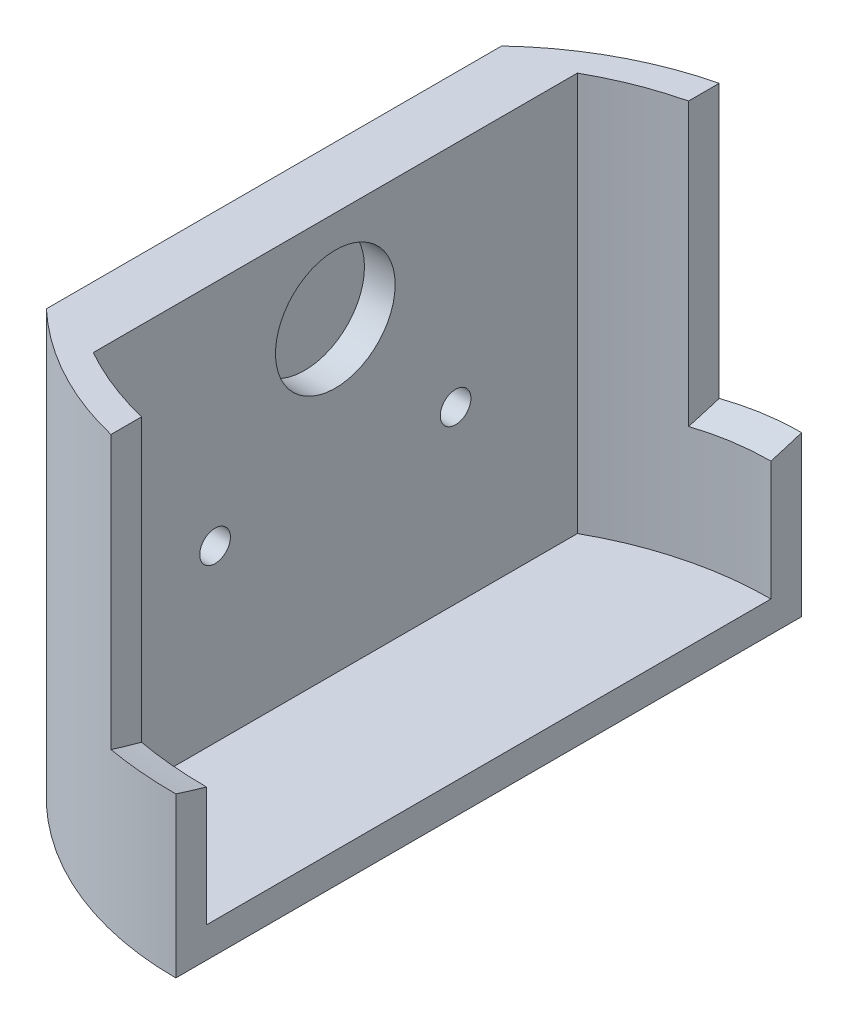
from build123d import *

# Parameters (mm, degrees)
BOSS_EXTRU_7_DEPTH      = 35
BOSS_EXTRU_8_START      = -5
BOSS_EXTRU_8_DEPTH      = 5
ESQUISSE3_R             = 2.4999999999999987
ENL_V_MAT_EXTRU_1_DEPTH = 5
ENL_V_MAT_EXTRU_2_DEPTH = 12
ESQUISSE6_R             = 9.75
ENL_V_MAT_EXTRU_3_DEPTH = 5


with BuildPart() as part:
    # Esquisse1 → Boss.-Extru.7 (new, symmetric)
    with BuildSketch(Plane(origin=(0, 0, 0), x_dir=(1, 0, 0), z_dir=(0, 1, 0))):
        with BuildLine():
            Line((0, 51.00000000000001), (1.188e-14, 46.00000000000001))
            ThreePointArc((1.188e-14, 46.00000000000001), (-12.921623376513631, 44.33590628857987), (-24.99999999999999, 39.45222154178573))
            Line((-24.99999999999999, 39.45222154178573), (-24.99999999999999, -39.45222154178573))
            ThreePointArc((-24.99999999999999, -39.45222154178573), (-12.921623376513633, -44.33590628857988), (1.188e-14, -46.00000000000001))
            Line((1.188e-14, -46.00000000000001), (0, -51.00000000000001))
            ThreePointArc((0, -51.00000000000001), (-18.830584522511188, -47.39629823668259), (-35, -37.09447398198281))
            Line((-35, -37.09447398198281), (-35, 37.09447398198281))
            ThreePointArc((-35, 37.09447398198281), (-18.830584522511195, 47.396298236682604), (0, 51.00000000000001))
        make_face()
    extrude(amount=BOSS_EXTRU_7_DEPTH, both=True)

    # Esquisse2 → Boss.-Extru.8 (add)
    with BuildSketch(Plane.XZ.offset(35).offset(BOSS_EXTRU_8_START)):
        with BuildLine():
            Line((-34.99999999999999, 37.094473981982816), (-34.99999999999999, -37.094473981982816))
            ThreePointArc((-34.99999999999999, -37.094473981982816), (-18.830584522511195, -47.396298236682604), (0, -51.00000000000001))
            Line((0, -51.00000000000001), (0, 51.00000000000001))
            ThreePointArc((0, 51.00000000000001), (-18.830584522511195, 47.396298236682604), (-34.99999999999999, 37.094473981982816))
        make_face()
    extrude(amount=BOSS_EXTRU_8_DEPTH)

    # Esquisse3 → Enlèv. mat.-Extru.1 (cut)
    with BuildSketch(Plane(origin=(-24.99999999999999, 0, 0), x_dir=(0, 0, -1), z_dir=(1, 0, 0))):
        with Locations((-19.600000000000012, -2.2100000000000035)):
            Circle(ESQUISSE3_R)
        with Locations((19.59999999999999, -2.209999999999999)):
            Circle(ESQUISSE3_R)
    extrude(amount=-ENL_V_MAT_EXTRU_1_DEPTH, mode=Mode.SUBTRACT)

    # Esquisse5 → Enlèv. mat.-Extru.2 (cut)
    with BuildSketch(Plane(origin=(0, 0, 0), x_dir=(2.38e-15, 0, -1), z_dir=(1, 0, 2.38e-15))):
        with BuildLine():
            Line((40.674477228026994, 51.032394682771525), (98.05120693404734, 14.815086571109495))
            ThreePointArc((98.05120693404734, 14.815086571109495), (1.023e-14, -17), (-98.05120693404734, 14.81508657110947))
            Line((-98.05120693404734, 14.81508657110947), (-40.674477228026994, 51.03239468277152))
            ThreePointArc((-40.674477228026994, 51.03239468277152), (6.55e-15, 43.000000000000014), (40.674477228026994, 51.032394682771525))
        make_face()
    extrude(amount=-ENL_V_MAT_EXTRU_2_DEPTH, mode=Mode.SUBTRACT)

    # Esquisse6 → Enlèv. mat.-Extru.3 (cut)
    with BuildSketch(Plane(origin=(-24.99999999999999, 0, 0), x_dir=(0, 0, -1), z_dir=(1, 0, 0))):
        with Locations((0, 20.000000000000004)):
            Circle(ESQUISSE6_R)
    extrude(amount=-ENL_V_MAT_EXTRU_3_DEPTH, mode=Mode.SUBTRACT)


solid = part.part
